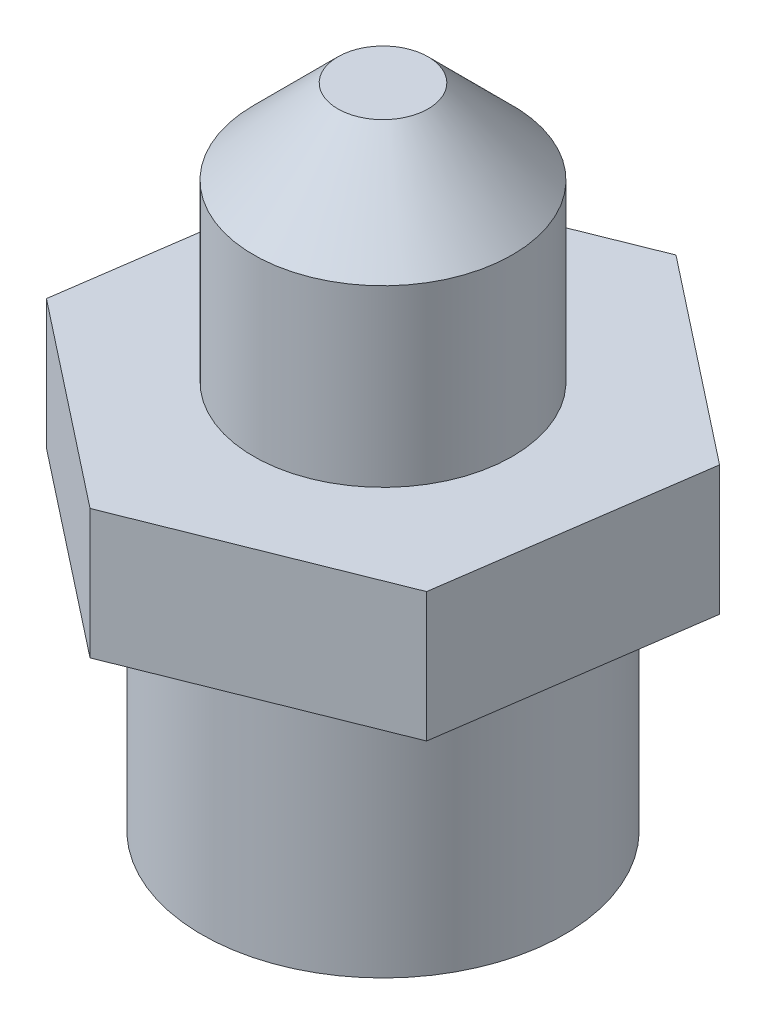
from build123d import *

# Parameters (mm, degrees)
SKETCH_2_OUTSIDE_W  = 29.55
SKETCH_2_OUTSIDE_H  = 29.55
CUT_EXTRUDE_1_DEPTH = 16


with BuildPart() as part:
    # Эскиз1 → Повернуть1 (revolve)
    with BuildSketch(Plane.XY):
        Polygon((0, 0), (7, 0), (7, 10), (10, 10), (10, 15), (5, 15), (5, 21.744186047), (1.744186047, 25), (0, 25), align=None)
    revolve(axis=Axis((0, 25, 0), (0, -1, 0)))

    # Эскиз2 outside → Вырез-Вытянуть1 (cut, through all)
    with BuildSketch(Plane(origin=(0, 15, 0), x_dir=(1, 0, 0), z_dir=(0, 1, 0))):
        Rectangle(SKETCH_2_OUTSIDE_W, SKETCH_2_OUTSIDE_H)
        Polygon((7.862707781, -6.178820789), (9.282369659, 3.719894287), (1.419661878, 9.898715076), (-7.862707781, 6.178820789), (-9.282369659, -3.719894287), (-1.419661878, -9.898715076), align=None, mode=Mode.SUBTRACT)
    extrude(amount=-CUT_EXTRUDE_1_DEPTH, mode=Mode.SUBTRACT)


solid = part.part
